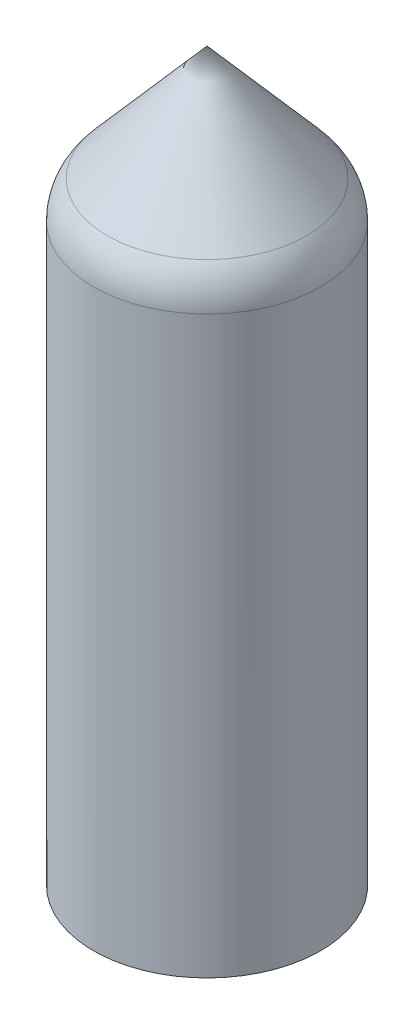
from build123d import *

# Parameters (mm, degrees)
REDONDEO1_R           = 10
CROQUIS4_R            = 1.65
CORTAR_EXTRUIR1_DEPTH = 5
CORTAR_EXTRUIR2_DEPTH = 2


with BuildPart() as part:
    # Croquis1 → Revolución3 (revolve)
    with BuildSketch(Plane.XY):
        Polygon((-20, -5), (-20, 100), (0, 123), (0, 120), (-17, 100), (-17, 0), (-10, 0), (-10, -5), align=None)
    revolve(axis=Axis((0, 0, 0), (0, 1, 0)))

    # Redondeo1
    redondeo1_edges = [part.edges().sort_by_distance(p)[0] for p in [
        (20, 100, 0),
    ]]
    fillet(redondeo1_edges, radius=REDONDEO1_R)

    # Croquis4 → Cortar-Extruir1 (cut)
    with BuildSketch(Plane.XZ.offset(5)):
        with Locations((12.5, 0)):
            Circle(CROQUIS4_R)
        with Locations((-12.5, 0)):
            Circle(CROQUIS4_R)
    extrude(amount=-CORTAR_EXTRUIR1_DEPTH, mode=Mode.SUBTRACT)

    # Croquis5 → Cortar-Extruir2 (cut)
    with BuildSketch(Plane(origin=(0, 0, 0), x_dir=(1, 0, 0), z_dir=(0, 1, 0))):
        Polygon((-12.5, 3.4), (-15.444486373, 1.7), (-15.444486373, -1.7), (-12.5, -3.4), (-9.555513627, -1.7), (-9.555513627, 1.7), align=None)
        Polygon((12.5, 3.4), (9.555513627, 1.7), (9.555513627, -1.7), (12.5, -3.4), (15.444486373, -1.7), (15.444486373, 1.7), align=None)
    extrude(amount=-CORTAR_EXTRUIR2_DEPTH, mode=Mode.SUBTRACT)


solid = part.part
